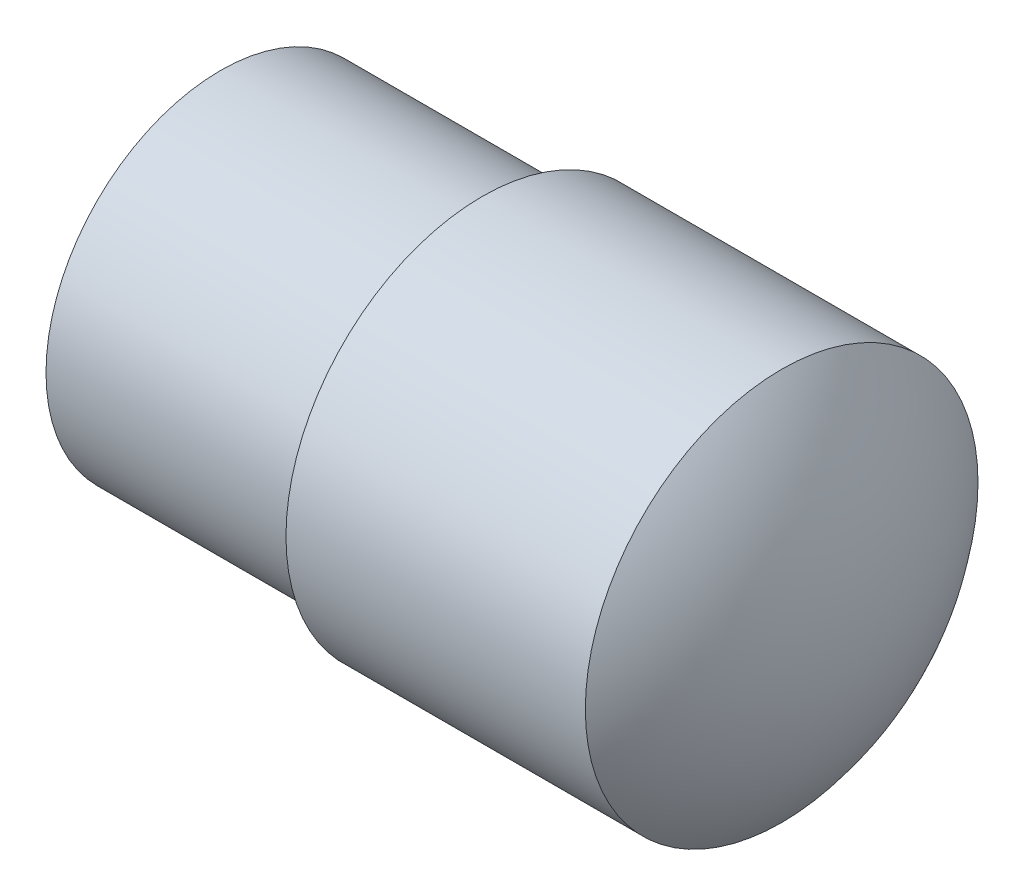
from build123d import *


with BuildPart() as part:
    # Esquisse1 → Révolution1 (revolve)
    with BuildSketch(Plane.XY, mode=Mode.PRIVATE) as r_volution1_sk:
        with BuildLine():
            Line((-117.412392243, 9), (-103.688586948, 9))
            ThreePointArc((-103.688586948, 9), (-101.256912887, 4.78887909), (-100.412392243, 0))
            Line((-100.412392243, 0), (-129.412392243, 0))
            Line((-129.412392243, 0), (-129.412392243, 8))
            Line((-129.412392243, 8), (-117.412392243, 8))
            Line((-117.412392243, 8), (-117.412392243, 9))
        make_face()
    revolve(r_volution1_sk.sketch.rotate(Axis((-129.412392243, 0, 0), (1, 0, 0)), 90), axis=Axis((-129.412392243, 0, 0), (1, 0, 0)))  # turned: the seam where the file's is

    # Esquisse2 → Enlèvement de matière-Révolution1 (revolve, cut)
    with BuildSketch(Plane.XY, mode=Mode.PRIVATE) as enl_vement_de_mati_re_r_volution1_sk:
        with BuildLine():
            Line((-109.412392243, -10.843650203), (-106.412392243, -10.843650203))
            Line((-106.412392243, -10.843650203), (-106.412392243, 0))
            ThreePointArc((-106.412392243, 0), (-107.291071899, 2.121320344), (-109.412392243, 3))
            Line((-109.412392243, 3), (-109.412392243, 0))
            Line((-109.412392243, 0), (-109.412392243, -10.843650203))
        make_face()
    revolve(enl_vement_de_mati_re_r_volution1_sk.sketch.rotate(Axis((-109.412392243, 10.689425153, 0), (0, -1, 0)), 90), axis=Axis((-109.412392243, 10.689425153, 0), (0, -1, 0)), mode=Mode.SUBTRACT)  # turned: the seam where the file's is


solid = part.part
